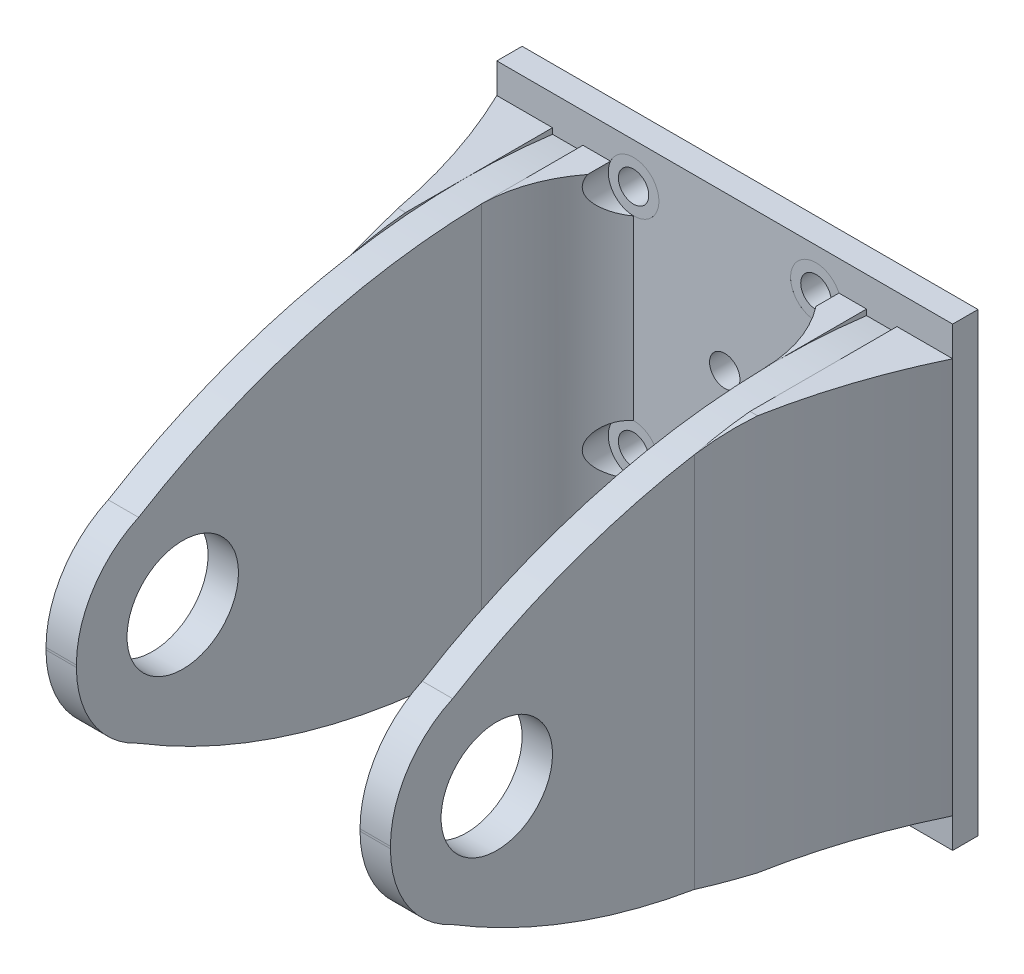
from build123d import *

# Parameters (mm, degrees)
SKETCH_1_W               = 45
SKETCH_1_H               = 45
EXTRUDE_1_DEPTH          = 2.5
EXTRUDE_2_DEPTH          = 50
SKETCH_3_R               = 5.5
CUT_EXTRUDE_1_DEPTH      = 80.633535649
CUT_EXTRUDE_2_DEPTH      = 80.633535649
SKETCH_5_W               = 5
SKETCH_5_H               = 39.075696326
EXTRUDE_3_DEPTH          = 10
CUT_EXTRUDE_3_DEPTH      = 81.922374398
SKETCH_7_W               = 5.5
SKETCH_7_H               = 39.075696326
EXTRUDE_4_DEPTH          = 20
CUT_EXTRUDE_4_DEPTH      = 83.5
CUT_EXTRUDE_5_DEPTH      = 81.922374398
CUT_EXTRUDE_7_REACH      = 84.5
SKETCH_12_R              = 1.5
SKETCH_12_R_2            = 1.525256865
SKETCH_12_R_3            = 1.450491537
CUT_EXTRUDE_8_DEPTH      = 10
CUT_EXTRUDE_8_DEPTH_BACK = 0.001
SKETCH_13_R              = 2.5


with BuildPart() as part:
    # 草图1 → 凸台-拉伸1 (new body)
    with BuildSketch(Plane.XY):
        with Locations((22.5, 22.5)):
            Rectangle(SKETCH_1_W, SKETCH_1_H)
    extrude(amount=EXTRUDE_1_DEPTH)

    # 草图2 → 凸台-拉伸2 (add)
    with BuildSketch(Plane.XY.offset(2.5)):
        Polygon((36.5, 22.5), (36.5, 0), (39.5, 0), (39.5, 45), (36.5, 45), align=None)
        Polygon((8.5, 45), (8.5, 22.5), (8.5, 0), (5.5, 0), (5.5, 45), align=None)
    extrude(amount=EXTRUDE_2_DEPTH)

    # 草图3 → 切除-拉伸1 (cut, through all)
    with BuildSketch(Plane(origin=(39.5, 0, 0), x_dir=(0, 0, -1), z_dir=(1, 0, 0))):
        with Locations((-42, 22.5)):
            Circle(SKETCH_3_R)
    extrude(amount=-CUT_EXTRUDE_1_DEPTH, mode=Mode.SUBTRACT)

    # 草图4 → 切除-拉伸2 (cut, through all)
    with BuildSketch(Plane(origin=(39.5, 0, 0), x_dir=(0, 0, -1), z_dir=(1, 0, 0))):
        with BuildLine():
            Line((-2.5, 45), (-2.5, 41.474247654))
            ThreePointArc((-2.5, 41.474247654), (-25.225749209, 40.564939101), (-46.358725725, 32.157571933))
            ThreePointArc((-46.358725725, 32.157571933), (-50.832231318, 28.283182945), (-52.5, 22.605006306))
            Line((-52.5, 22.605006306), (-52.5, 45))
            Line((-52.5, 45), (-2.5, 45))
        make_face()
        with BuildLine():
            Line((-52.5, 22.394993694), (-52.5, 0))
            Line((-52.5, 0), (-2.5, 0))
            Line((-2.5, 0), (-2.5, 3.525752346))
            ThreePointArc((-2.5, 3.525752346), (-25.225749209, 4.435060899), (-46.358725725, 12.842428067))
            ThreePointArc((-46.358725725, 12.842428067), (-50.832231318, 16.716817055), (-52.5, 22.394993694))
        make_face()
    extrude(amount=-CUT_EXTRUDE_2_DEPTH, mode=Mode.SUBTRACT)

    # 草图5 → 凸台-拉伸3 (add)
    with BuildSketch(Plane.XY.offset(2.5)):
        with Locations((11, 22.5)):
            Rectangle(SKETCH_5_W, SKETCH_5_H)
        with Locations((34, 22.5)):
            Rectangle(SKETCH_5_W, SKETCH_5_H)
    extrude(amount=EXTRUDE_3_DEPTH)

    # 草图6 → 切除-拉伸3 (cut, through all)
    with BuildSketch(Plane(origin=(0, 42.037848163, 0), x_dir=(1, 0, 0), z_dir=(0, 1, 0))):
        with BuildLine():
            Line((13.5, -2.5), (13.5, -12.5))
            Line((13.5, -12.5), (8.5, -12.5))
            ThreePointArc((8.5, -12.5), (9.861833326, -6.930916663), (13.5, -2.5))
        make_face()
        with BuildLine():
            Line((31.5, -2.5), (31.5, -12.5))
            Line((31.5, -12.5), (36.5, -12.5))
            ThreePointArc((36.5, -12.5), (35.138166674, -6.930916663), (31.5, -2.5))
        make_face()
    extrude(amount=-CUT_EXTRUDE_3_DEPTH, mode=Mode.SUBTRACT)

    # 草图7 → 凸台-拉伸4 (add)
    with BuildSketch(Plane.XY.offset(2.5)):
        with Locations((2.75, 22.5)):
            Rectangle(SKETCH_7_W, SKETCH_7_H)
        with Locations((42.25, 22.5)):
            Rectangle(SKETCH_7_W, SKETCH_7_H)
    extrude(amount=EXTRUDE_4_DEPTH)

    # 草图8 → 切除-拉伸4 (cut, through all)
    with BuildSketch(Plane(origin=(45, 0, 0), x_dir=(0, 0, -1), z_dir=(1, 0, 0))):
        with BuildLine():
            Line((-22.5, 41.085625399), (-22.5, 42.037848163))
            Line((-22.5, 42.037848163), (-17.008220021, 42.037848163))
            ThreePointArc((-17.008220021, 42.037848163), (-19.771631621, 41.662789638), (-22.5, 41.085625399))
        make_face()
        with BuildLine():
            Line((-22.5, 3.914374601), (-22.5, 2.962151837))
            Line((-22.5, 2.962151837), (-17.008220021, 2.962151837))
            ThreePointArc((-17.008220021, 2.962151837), (-19.771631621, 3.337210362), (-22.5, 3.914374601))
        make_face()
    extrude(amount=-CUT_EXTRUDE_4_DEPTH, mode=Mode.SUBTRACT)

    # 草图9 → 切除-拉伸5 (cut, through all)
    with BuildSketch(Plane(origin=(0, 2.962151837, 0), x_dir=(-1, 0, 0), z_dir=(0, -1, 0))):
        with BuildLine():
            Line((-39.5, -22.5), (-45, -22.5))
            Line((-45, -22.5), (-45, -2.5))
            ThreePointArc((-45, -2.5), (-41.339785895, -12.249691121), (-39.5, -22.5))
        make_face()
        with BuildLine():
            Line((-5.5, -22.5), (0, -22.5))
            Line((0, -22.5), (0, -2.5))
            ThreePointArc((0, -2.5), (-3.660214105, -12.249691121), (-5.5, -22.5))
        make_face()
    extrude(amount=-CUT_EXTRUDE_5_DEPTH, mode=Mode.SUBTRACT)

    # 草图12 → 切除-拉伸7 (cut, up to next)
    with BuildSketch(Plane(origin=(0, 0, 0), x_dir=(-1, 0, 0), z_dir=(0, 0, -1)), mode=Mode.PRIVATE) as cut_extrude_7_sk1:
        with Locations((-13.5, 18.5)):
            Circle(SKETCH_12_R)
    cut_extrude_7_tool1 = extrude(cut_extrude_7_sk1.sketch, amount=-CUT_EXTRUDE_7_REACH, mode=Mode.PRIVATE) & part.part
    # 草图12 → 切除-拉伸7 (cut, up to next)
    with BuildSketch(Plane(origin=(0, 0, 0), x_dir=(-1, 0, 0), z_dir=(0, 0, -1)), mode=Mode.PRIVATE) as cut_extrude_7_sk2:
        with Locations((-13.5, 6.5)):
            Circle(SKETCH_12_R_2)
    cut_extrude_7_tool2 = extrude(cut_extrude_7_sk2.sketch, amount=-CUT_EXTRUDE_7_REACH, mode=Mode.PRIVATE) & part.part
    # 草图12 → 切除-拉伸7 (cut, up to next)
    with BuildSketch(Plane(origin=(0, 0, 0), x_dir=(-1, 0, 0), z_dir=(0, 0, -1)), mode=Mode.PRIVATE) as cut_extrude_7_sk3:
        with Locations((-31.5, 18.5)):
            Circle(SKETCH_12_R)
    cut_extrude_7_tool3 = extrude(cut_extrude_7_sk3.sketch, amount=-CUT_EXTRUDE_7_REACH, mode=Mode.PRIVATE) & part.part
    # 草图12 → 切除-拉伸7 (cut, up to next)
    with BuildSketch(Plane(origin=(0, 0, 0), x_dir=(-1, 0, 0), z_dir=(0, 0, -1)), mode=Mode.PRIVATE) as cut_extrude_7_sk4:
        with Locations((-31.5, 6.5)):
            Circle(SKETCH_12_R_3)
    cut_extrude_7_tool4 = extrude(cut_extrude_7_sk4.sketch, amount=-CUT_EXTRUDE_7_REACH, mode=Mode.PRIVATE) & part.part
    # 草图12 → 切除-拉伸7 (cut, up to next)
    with BuildSketch(Plane(origin=(0, 0, 0), x_dir=(-1, 0, 0), z_dir=(0, 0, -1)), mode=Mode.PRIVATE) as cut_extrude_7_sk5:
        with Locations((-13.5, 41)):
            Circle(SKETCH_12_R)
    cut_extrude_7_tool5 = extrude(cut_extrude_7_sk5.sketch, amount=-CUT_EXTRUDE_7_REACH, mode=Mode.PRIVATE) & part.part
    # 草图12 → 切除-拉伸7 (cut, up to next)
    with BuildSketch(Plane(origin=(0, 0, 0), x_dir=(-1, 0, 0), z_dir=(0, 0, -1)), mode=Mode.PRIVATE) as cut_extrude_7_sk6:
        with Locations((-31.5, 41)):
            Circle(SKETCH_12_R)
    cut_extrude_7_tool6 = extrude(cut_extrude_7_sk6.sketch, amount=-CUT_EXTRUDE_7_REACH, mode=Mode.PRIVATE) & part.part
    # 草图12 → 切除-拉伸7 (cut, up to next)
    with BuildSketch(Plane(origin=(0, 0, 0), x_dir=(-1, 0, 0), z_dir=(0, 0, -1)), mode=Mode.PRIVATE) as cut_extrude_7_sk7:
        with Locations((-22.5, 29.75)):
            Circle(SKETCH_12_R)
    cut_extrude_7_tool7 = extrude(cut_extrude_7_sk7.sketch, amount=-CUT_EXTRUDE_7_REACH, mode=Mode.PRIVATE) & part.part
    add(cut_extrude_7_tool1.solids().sort_by_distance((13.5, 18.5, 0))[0], mode=Mode.SUBTRACT)
    add(cut_extrude_7_tool2.solids().sort_by_distance((13.5, 6.5, 0))[0], mode=Mode.SUBTRACT)
    add(cut_extrude_7_tool3.solids().sort_by_distance((31.5, 18.5, 0))[0], mode=Mode.SUBTRACT)
    add(cut_extrude_7_tool4.solids().sort_by_distance((31.5, 6.5, 0))[0], mode=Mode.SUBTRACT)
    add(cut_extrude_7_tool5.solids().sort_by_distance((13.5, 41, 0))[0], mode=Mode.SUBTRACT)
    add(cut_extrude_7_tool6.solids().sort_by_distance((31.5, 41, 0))[0], mode=Mode.SUBTRACT)
    add(cut_extrude_7_tool7.solids().sort_by_distance((22.5, 29.75, 0))[0], mode=Mode.SUBTRACT)

    # 草图13 → 切除-拉伸8 (cut, two sides: drawn at the far end of the back side and taken through both)
    with BuildSketch(Plane.XY.offset(2.5).offset(-CUT_EXTRUDE_8_DEPTH_BACK)):
        with Locations(Location((13.5, 6.5, 0), (0, 0, 180))):
            Circle(SKETCH_13_R)
        with Locations(Location((13.5, 18.5, 0), (0, 0, 180))):
            Circle(SKETCH_13_R)
        with Locations(Location((13.5, 41, 0), (0, 0, 180))):
            Circle(SKETCH_13_R)
        with Locations(Location((31.5, 41, 0), (0, 0, 180))):
            Circle(SKETCH_13_R)
        with Locations(Location((31.5, 18.5, 0), (0, 0, 180))):
            Circle(SKETCH_13_R)
        with Locations(Location((31.5, 6.5, 0), (0, 0, 180))):
            Circle(SKETCH_13_R)
    extrude(amount=CUT_EXTRUDE_8_DEPTH + CUT_EXTRUDE_8_DEPTH_BACK, mode=Mode.SUBTRACT)


solid = part.part
